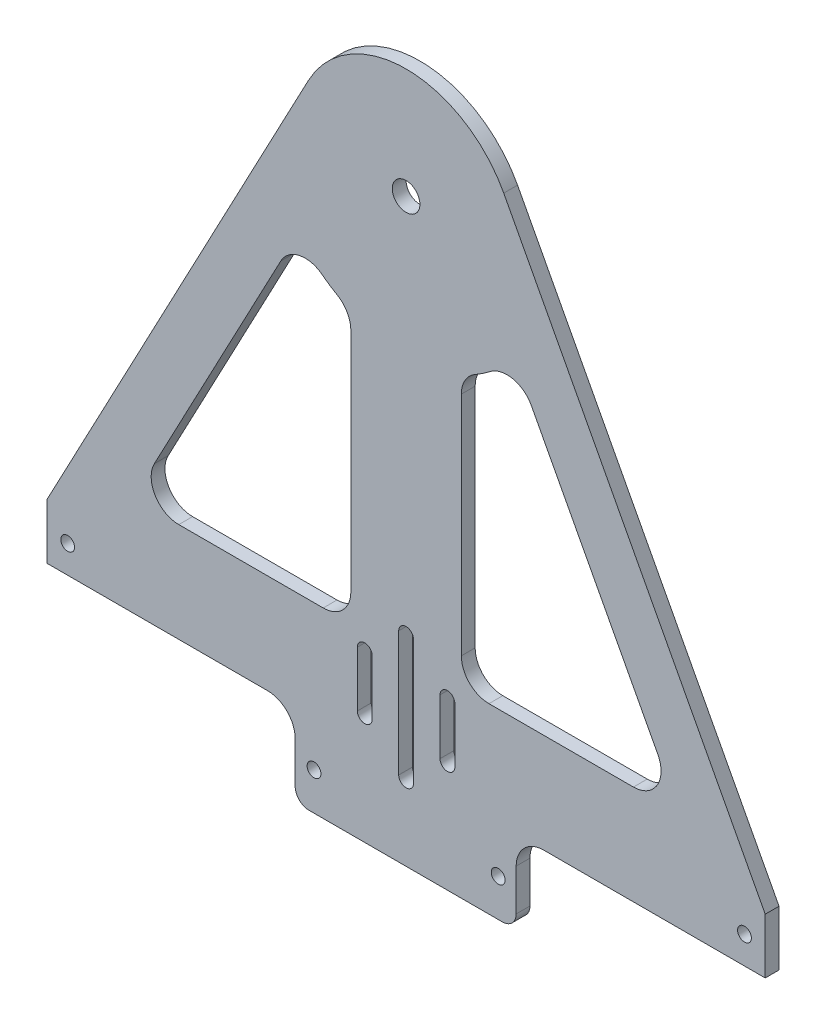
from build123d import *

# Parameters (mm, degrees)
SKETCH5_R           = 1.5875
SKETCH5_R_2         = 3.175
BOSS_EXTRUDE2_DEPTH = 3.175


with BuildPart() as part:
    # Sketch5 → Boss-Extrude2 (new body)
    with BuildSketch(Plane.XY):
        with BuildLine():
            Line((-82.55, 70.885609673), (-82.55, 58.185609673))
            Line((-82.55, 58.185609673), (-31.848963051, 58.185609673))
            ThreePointArc((-31.848963051, 58.185609673), (-27.35883499, 56.325737733), (-25.498963051, 51.835609673))
            Line((-25.498963051, 51.835609673), (-25.498963051, 42.310609673))
            ThreePointArc((-25.498963051, 42.310609673), (-24.569027081, 40.065545642), (-22.323963051, 39.135609673))
            Line((-22.323963051, 39.135609673), (22.126036949, 39.135609673))
            ThreePointArc((22.126036949, 39.135609673), (24.37110098, 40.065545642), (25.301036949, 42.310609673))
            Line((25.301036949, 42.310609673), (25.301036949, 51.835609673))
            ThreePointArc((25.301036949, 51.835609673), (27.160908889, 56.325737733), (31.651036949, 58.185609673))
            Line((31.651036949, 58.185609673), (82.55, 58.185609673))
            Line((82.55, 58.185609673), (82.55, 70.885609673))
            Line((82.55, 70.885609673), (22.446426721, 184.373331383))
            ThreePointArc((22.446426721, 184.373331383), (0, 197.885609673), (-22.446426721, 184.373331383))
            Line((-22.446426721, 184.373331383), (-82.55, 70.885609673))
        make_face()
        with Locations((-77.7875, 64.535609673)):
            Circle(SKETCH5_R, mode=Mode.SUBTRACT)
        with Locations((77.7875, 64.535609673)):
            Circle(SKETCH5_R, mode=Mode.SUBTRACT)
        with Locations((-21.166666667, 47.762966307)):
            Circle(SKETCH5_R, mode=Mode.SUBTRACT)
        with Locations((21.166666667, 47.762966307)):
            Circle(SKETCH5_R, mode=Mode.SUBTRACT)
        with Locations((0, 172.485609673)):
            Circle(SKETCH5_R_2, mode=Mode.SUBTRACT)
        with BuildLine():
            Line((-57.861180964, 90.3675401), (-28.80539088, 145.230757697))
            ThreePointArc((-28.80539088, 145.230757697), (-24.546211379, 148.463135508), (-19.3281535, 147.296624336))
            ThreePointArc((-19.3281535, 147.296624336), (-17.639343437, 146.086441824), (-15.875, 144.989303103))
            ThreePointArc((-15.875, 144.989303103), (-13.550738686, 142.665041789), (-12.7, 139.490041789))
            Line((-12.7, 139.490041789), (-12.7, 87.395609673))
            ThreePointArc((-12.7, 87.395609673), (-14.559871939, 82.905481612), (-19.05, 81.045609673))
            Line((-19.05, 81.045609673), (-52.249574284, 81.045609673))
            ThreePointArc((-52.249574284, 81.045609673), (-57.689898641, 84.120648468), (-57.861180964, 90.3675401))
        make_face(mode=Mode.SUBTRACT)
        with BuildLine():
            Line((57.861180964, 90.3675401), (28.80539088, 145.230757697))
            ThreePointArc((28.80539088, 145.230757697), (24.546211379, 148.463135508), (19.3281535, 147.296624336))
            ThreePointArc((19.3281535, 147.296624336), (17.639343437, 146.086441824), (15.875, 144.989303103))
            ThreePointArc((15.875, 144.989303103), (13.550738686, 142.665041789), (12.7, 139.490041789))
            Line((12.7, 139.490041789), (12.7, 87.395609673))
            ThreePointArc((12.7, 87.395609673), (14.559871939, 82.905481612), (19.05, 81.045609673))
            Line((19.05, 81.045609673), (52.249574284, 81.045609673))
            ThreePointArc((52.249574284, 81.045609673), (57.689898641, 84.120648468), (57.861180964, 90.3675401))
        make_face(mode=Mode.SUBTRACT)
        with BuildLine():
            Line((-11.2, 64.474125728), (-11.2, 77.174125728))
            ThreePointArc((-11.2, 77.174125728), (-9.5, 78.874125728), (-7.8, 77.174125728))
            Line((-7.8, 77.174125728), (-7.8, 64.474125728))
            ThreePointArc((-7.8, 64.474125728), (-9.5, 62.774125728), (-11.2, 64.474125728))
        make_face(mode=Mode.SUBTRACT)
        with BuildLine():
            Line((-1.7, 56.474125728), (-1.7, 85.174125728))
            ThreePointArc((-1.7, 85.174125728), (0, 86.874125728), (1.7, 85.174125728))
            Line((1.7, 85.174125728), (1.7, 56.474125728))
            ThreePointArc((1.7, 56.474125728), (0, 54.774125728), (-1.7, 56.474125728))
        make_face(mode=Mode.SUBTRACT)
        with BuildLine():
            Line((7.8, 64.474125728), (7.8, 77.174125728))
            ThreePointArc((7.8, 77.174125728), (9.5, 78.874125728), (11.2, 77.174125728))
            Line((11.2, 77.174125728), (11.2, 64.474125728))
            ThreePointArc((11.2, 64.474125728), (9.5, 62.774125728), (7.8, 64.474125728))
        make_face(mode=Mode.SUBTRACT)
    extrude(amount=BOSS_EXTRUDE2_DEPTH)


solid = part.part
